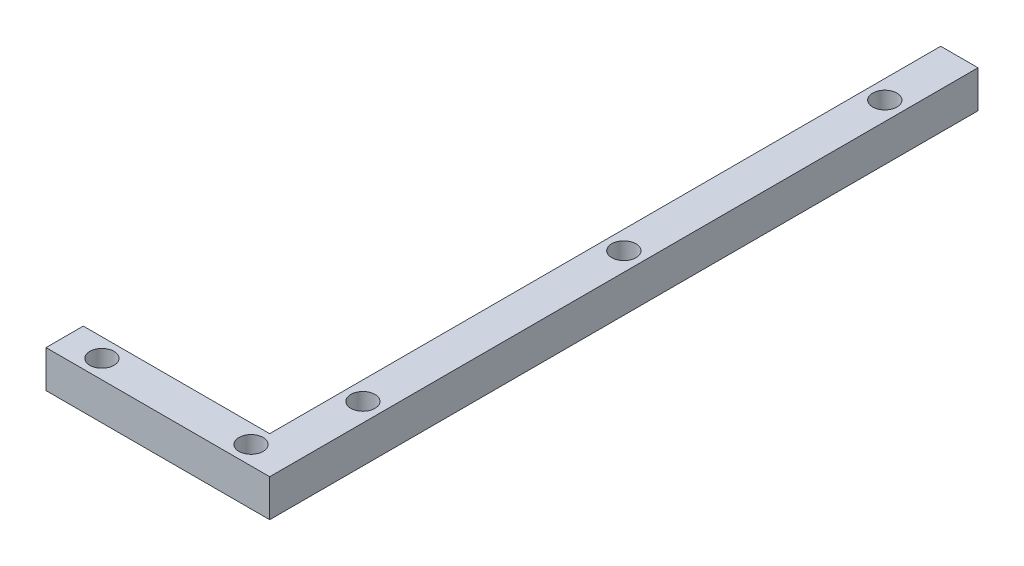
from build123d import *

# Parameters (mm, degrees)
BOSS_EXTRUDE1_DEPTH = 10
SKETCH2_R           = 3.25
CUT_EXTRUDE1_DEPTH  = 11


with BuildPart() as part:
    # Sketch1 → Boss-Extrude1 (new body)
    with BuildSketch(Plane(origin=(0, 0, 0), x_dir=(1, 0, 0), z_dir=(0, 1, 0))):
        Polygon((0, 0), (0, 180), (10, 180), (10, -10), (-50, -10), (-50, 0), align=None)
    extrude(amount=BOSS_EXTRUDE1_DEPTH)

    # Sketch2 → Cut-Extrude1 (cut, through all)
    with BuildSketch(Plane(origin=(0, 10, 0), x_dir=(1, 0, 0), z_dir=(0, 1, 0))):
        with Locations(Location((5, 160, 0), (0, 0, 270))):  # turned: the seam where the file's is
            Circle(SKETCH2_R)
        with Locations(Location((5, 90, 0), (0, 0, 270))):  # turned: the seam where the file's is
            Circle(SKETCH2_R)
        with Locations(Location((5, 20, 0), (0, 0, 270))):  # turned: the seam where the file's is
            Circle(SKETCH2_R)
        with Locations(Location((-40, -5, 0), (0, 0, 270))):  # turned: the seam where the file's is
            Circle(SKETCH2_R)
        with Locations(Location((0, -5, 0), (0, 0, 270))):  # turned: the seam where the file's is
            Circle(SKETCH2_R)
    extrude(amount=-CUT_EXTRUDE1_DEPTH, mode=Mode.SUBTRACT)


solid = part.part
